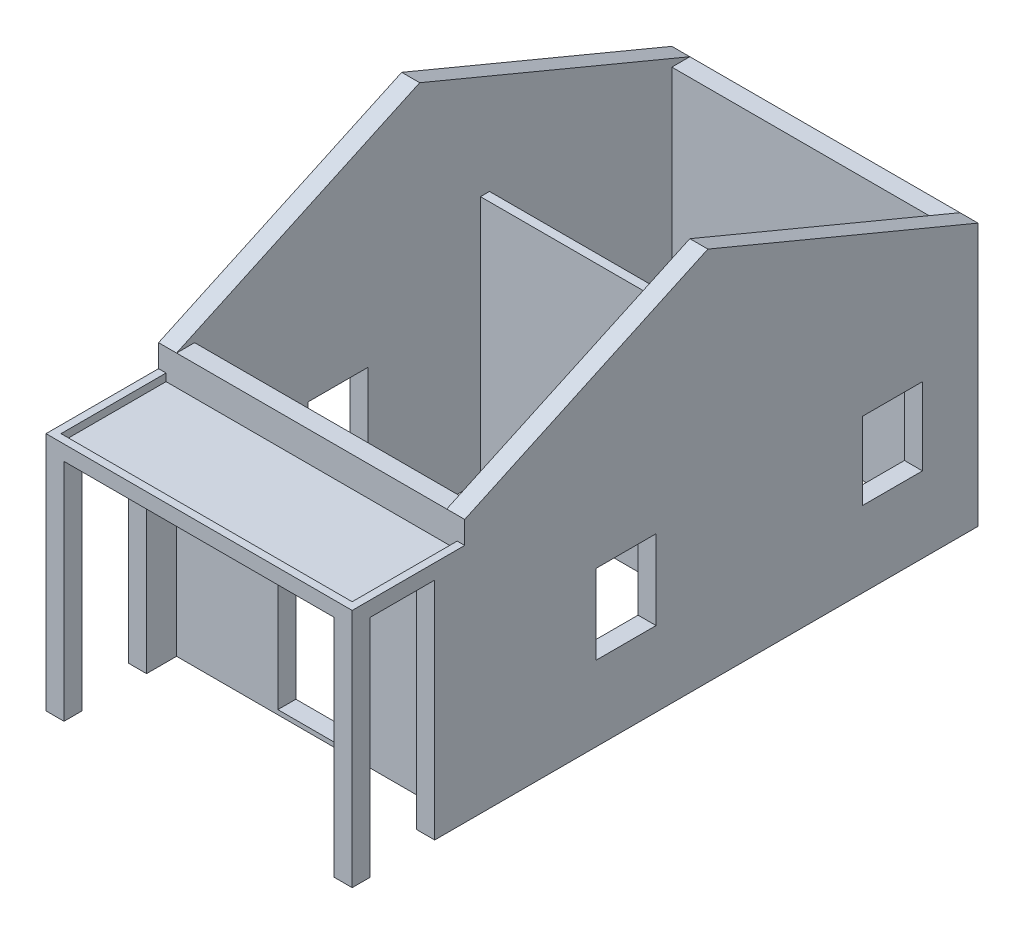
from build123d import *

# Parameters (mm, degrees)
SKETCH_1_W             = 4080
SKETCH_1_H             = 6840
SKETCH_1_W_2           = 3600
SKETCH_1_H_2           = 6360
EXTRUDE_525_DEPTH      = 3500
EXTRUDE_763_DEPTH      = 240
SKETCH_6_W             = 3600
SKETCH_6_H             = 120
EXTRUDE_1086_DEPTH     = 3280
SKETCH_12_W            = 1440
SKETCH_12_H            = 120
EXTRUDE_1316_DEPTH     = 2520
CUT_EXTRUDE_1552_REACH = 2792
SKETCH_10_W            = 1000
SKETCH_10_H            = 2050
SKETCH_4_W             = 800
SKETCH_4_H             = 1030
CUT_EXTRUDE_1996_DEPTH = 241
CUT_EXTRUDE_2338_REACH = 6842
SKETCH_13_W            = 1000
SKETCH_13_H            = 2520
SKETCH_15_W            = 1500
SKETCH_15_H            = 100
EXTRUDE_2583_DEPTH     = 4080
SKETCH_16_W            = 240
SKETCH_16_H            = 400
SKETCH_16_H_2          = 240
EXTRUDE_2839_DEPTH     = 3100
EXTRUDE_3047_DEPTH     = 100
SKETCH_18_W            = 800
SKETCH_18_H            = 1060
CUT_EXTRUDE_3409_DEPTH = 4081


with BuildPart() as part:
    # 草图1 → Extrude 525 (new body)
    with BuildSketch(Plane(origin=(0, 0, 0), x_dir=(1, 0, 0), z_dir=(0, 1, 0))):
        with Locations((-1800, 3180)):
            Rectangle(SKETCH_1_W, SKETCH_1_H)
        with Locations((-1800, 3180)):
            Rectangle(SKETCH_1_W_2, SKETCH_1_H_2, mode=Mode.SUBTRACT)
    extrude(amount=EXTRUDE_525_DEPTH)

    # 草图14 → Extrude 763 (add)
    with BuildSketch(Plane(origin=(240, 0, 0), x_dir=(0, 0, -1), z_dir=(1, 0, 0))):
        Polygon((-240, 3500), (3000, 5000), (6600, 3500), align=None)
    extrude_763 = extrude(amount=-EXTRUDE_763_DEPTH)

    # 镜向1: Extrude 763 across plane
    add(extrude_763.mirror(Plane(origin=(-1800, 0, 0), x_dir=(0, 0, 1), z_dir=(1, 0, 0))))

    # 草图6 → Extrude 1086 (add)
    with BuildSketch(Plane(origin=(0, 0, 0), x_dir=(1, 0, 0), z_dir=(0, 1, 0))):
        with Locations((-1800, 3870)):
            Rectangle(SKETCH_6_W, SKETCH_6_H)
    extrude(amount=EXTRUDE_1086_DEPTH)

    # 草图12 → Extrude 1316 (add)
    with BuildSketch(Plane(origin=(0, 0, 0), x_dir=(1, 0, 0), z_dir=(0, 1, 0))):
        with Locations((-720, 3990)):
            Rectangle(SKETCH_12_W, SKETCH_12_H)
    extrude(amount=EXTRUDE_1316_DEPTH)

    # 草图10 → Cut-Extrude 1552 (cut, up to next)
    with BuildSketch(Plane.XY.offset(-3810), mode=Mode.PRIVATE) as cut_extrude_1552_sk1:
        with Locations((-700, 1025)):
            Rectangle(SKETCH_10_W, SKETCH_10_H)
    cut_extrude_1552_tool1 = extrude(cut_extrude_1552_sk1.sketch, amount=-CUT_EXTRUDE_1552_REACH, mode=Mode.PRIVATE) & part.part
    add(cut_extrude_1552_tool1.solids().sort_by_distance((-700, 1025, -3810))[0], mode=Mode.SUBTRACT)

    # 草图4 → Cut-Extrude 1996 (cut, through all)
    with BuildSketch(Plane(origin=(0, 0, -11000), x_dir=(0, 0, 1), z_dir=(-1, 0, 0))):
        with Locations((5540, 1525)):
            Rectangle(SKETCH_4_W, SKETCH_4_H)
    extrude(amount=-CUT_EXTRUDE_1996_DEPTH, mode=Mode.SUBTRACT)

    # 草图13 → Cut-Extrude 2338 (cut, up to next)
    with BuildSketch(Plane.XY.offset(240), mode=Mode.PRIVATE) as cut_extrude_2338_sk1:
        with Locations((-1750, 1320)):
            Rectangle(SKETCH_13_W, SKETCH_13_H)
    cut_extrude_2338_tool1 = extrude(cut_extrude_2338_sk1.sketch, amount=-CUT_EXTRUDE_2338_REACH, mode=Mode.PRIVATE) & part.part
    add(cut_extrude_2338_tool1.solids().sort_by_distance((-1750, 1320, 240))[0], mode=Mode.SUBTRACT)

    # 草图15 → Extrude 2583 (add)
    with BuildSketch(Plane(origin=(240, 0, 0), x_dir=(0, 0, -1), z_dir=(1, 0, 0))):
        with Locations((-990, 3050)):
            Rectangle(SKETCH_15_W, SKETCH_15_H)
    extrude(amount=-EXTRUDE_2583_DEPTH)

    # 草图16 → Extrude 2839 (add)
    with BuildSketch(Plane(origin=(0, 3100, 0), x_dir=(1, 0, 0), z_dir=(0, 1, 0))):
        with Locations((120, -440)):
            Rectangle(SKETCH_16_W, SKETCH_16_H)
        with Locations((120, -1620)):
            Rectangle(SKETCH_16_W, SKETCH_16_H_2)
    extrude_2839 = extrude(amount=-EXTRUDE_2839_DEPTH)

    # Mirror 2899: Extrude 2839 across plane
    add(extrude_2839.mirror(Plane(origin=(-1800, 0, 0), x_dir=(0, 0, 1), z_dir=(1, 0, 0))))

    # 草图17 → Extrude 3047 (add)
    with BuildSketch(Plane(origin=(0, 3100, 0), x_dir=(1, 0, 0), z_dir=(0, 1, 0))):
        Polygon((240, -240), (240, -1740), (-3840, -1740), (-3840, -240), (-3740, -240), (-3740, -1640), (140, -1640), (140, -240), align=None)
    extrude(amount=EXTRUDE_3047_DEPTH)

    # 草图18 → Cut-Extrude 3409 (cut, through all)
    with BuildSketch(Plane(origin=(240, 0, 0), x_dir=(0, 0, -1), z_dir=(1, 0, 0))):
        with Locations((1910, 1530)):
            Rectangle(SKETCH_18_W, SKETCH_18_H)
    extrude(amount=-CUT_EXTRUDE_3409_DEPTH, mode=Mode.SUBTRACT)


solid = part.part
